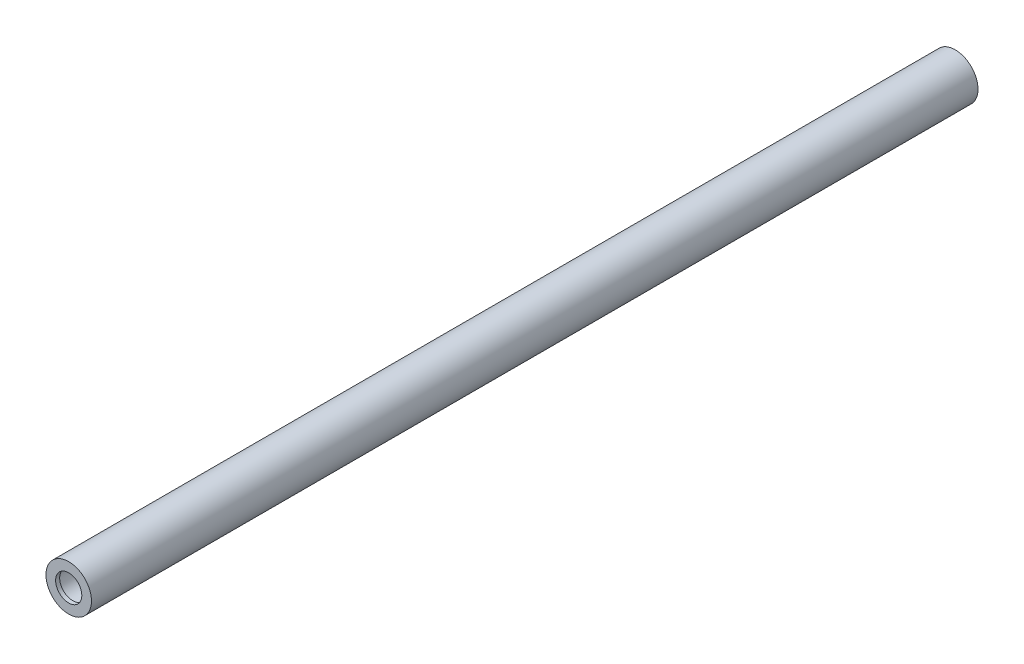
from build123d import *

# Parameters (mm, degrees)
SKETCH1_R           = 11.295
BOSS_EXTRUDE1_DEPTH = 440
SKETCH4_R           = 6.5
CUT_EXTRUDE4_DEPTH  = 2
SKETCH5_R           = 7.5
CUT_EXTRUDE5_DEPTH  = 15
SKETCH6_R           = 6.5
CUT_EXTRUDE7_DEPTH  = 2
SKETCH8_R           = 7.5
CUT_EXTRUDE8_DEPTH  = 15


with BuildPart() as part:
    # Sketch1 → Boss-Extrude1 (new body)
    with BuildSketch(Plane.XY):
        Circle(SKETCH1_R)
    extrude(amount=BOSS_EXTRUDE1_DEPTH)

    # Sketch4 → Cut-Extrude4 (cut)
    with BuildSketch(Plane(origin=(0, 0, 0), x_dir=(-1, 0, 0), z_dir=(0, 0, -1))):
        Circle(SKETCH4_R)
    extrude(amount=-CUT_EXTRUDE4_DEPTH, mode=Mode.SUBTRACT)

    # Sketch5 → Cut-Extrude5 (cut)
    with BuildSketch(Plane(origin=(0, 0, 2), x_dir=(-1, 0, 0), z_dir=(0, 0, -1))):
        Circle(SKETCH5_R)
    extrude(amount=-CUT_EXTRUDE5_DEPTH, mode=Mode.SUBTRACT)

    # Sketch6 → Cut-Extrude7 (cut)
    with BuildSketch(Plane.XY.offset(440)):
        Circle(SKETCH6_R)
    extrude(amount=-CUT_EXTRUDE7_DEPTH, mode=Mode.SUBTRACT)

    # Sketch8 → Cut-Extrude8 (cut)
    with BuildSketch(Plane.XY.offset(438)):
        Circle(SKETCH8_R)
    extrude(amount=-CUT_EXTRUDE8_DEPTH, mode=Mode.SUBTRACT)


solid = part.part
